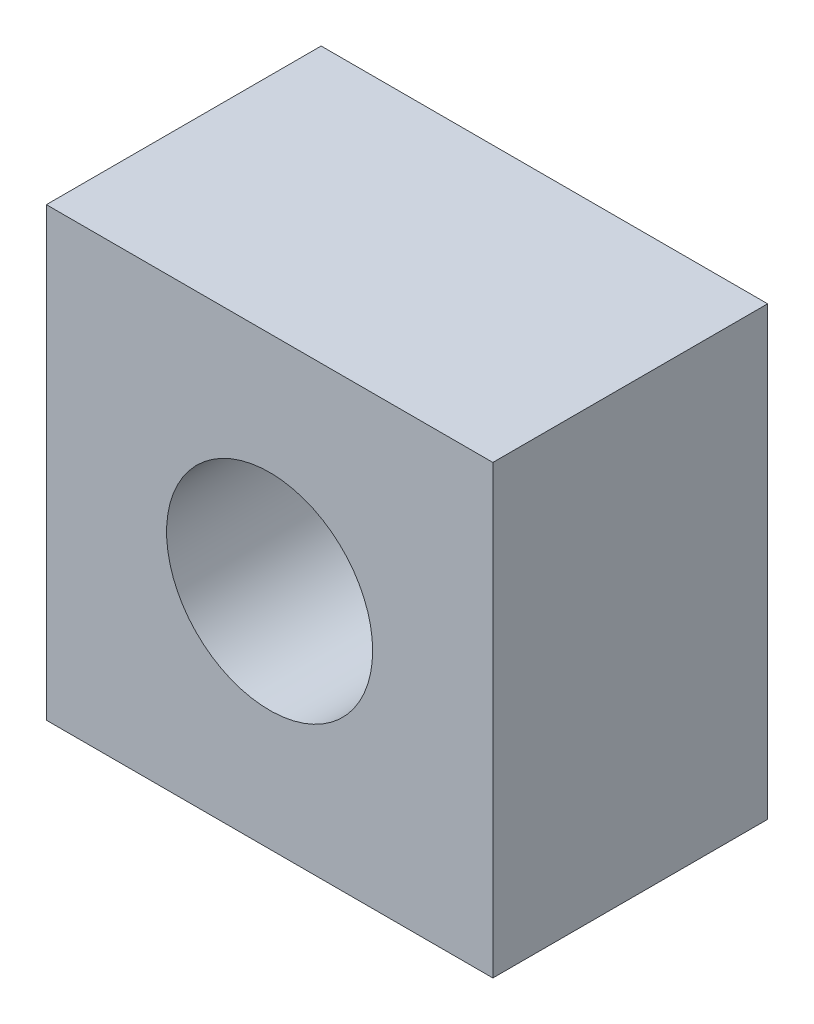
from build123d import *

# Parameters (mm, degrees)
SKETCH1_W           = 13
SKETCH1_H           = 13
BOSS_EXTRUDE1_DEPTH = 8
SKETCH2_R           = 3
CUT_EXTRUDE1_DEPTH  = 8


with BuildPart() as part:
    # Sketch1 → Boss-Extrude1 (new body)
    with BuildSketch(Plane.XY):
        with Locations((6.5, 6.5)):
            Rectangle(SKETCH1_W, SKETCH1_H)
    extrude(amount=BOSS_EXTRUDE1_DEPTH)

    # Sketch2 → Cut-Extrude1 (cut)
    with BuildSketch(Plane.XY.offset(8)):
        with Locations((6.5, 6.5)):
            Circle(SKETCH2_R)
    extrude(amount=-CUT_EXTRUDE1_DEPTH, mode=Mode.SUBTRACT)


solid = part.part
